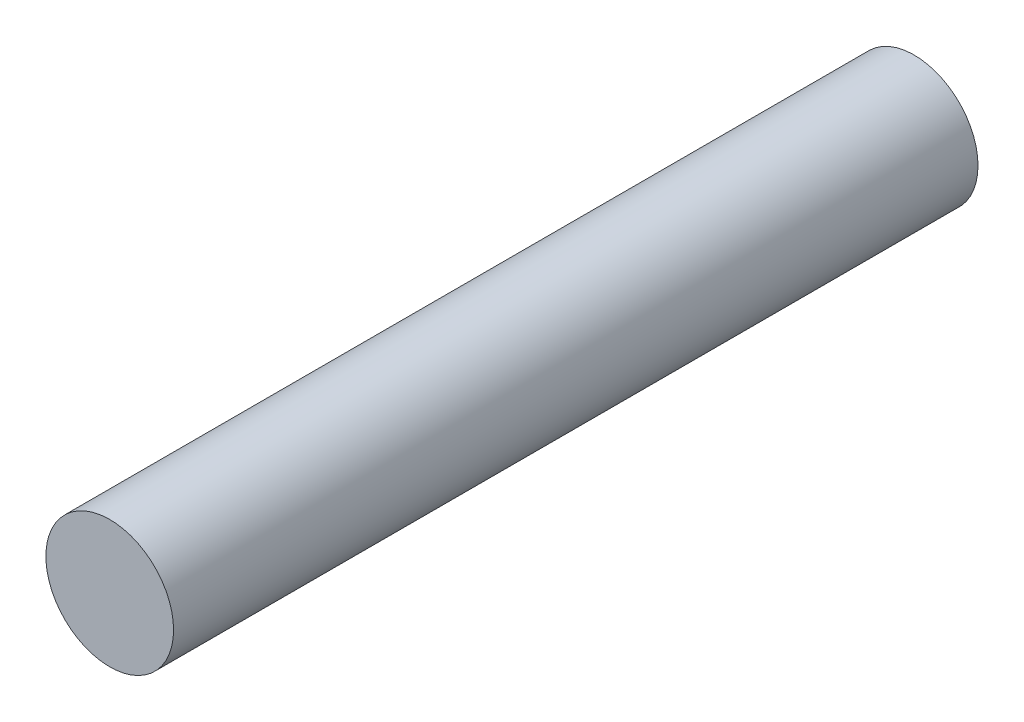
from build123d import *

# Parameters (mm, degrees)
SKETCH1_R           = 5
BOSS_EXTRUDE1_DEPTH = 63


with BuildPart() as part:
    # Sketch1 → Boss-Extrude1 (new body)
    with BuildSketch(Plane.XY):
        Circle(SKETCH1_R)
    extrude(amount=BOSS_EXTRUDE1_DEPTH)


solid = part.part
